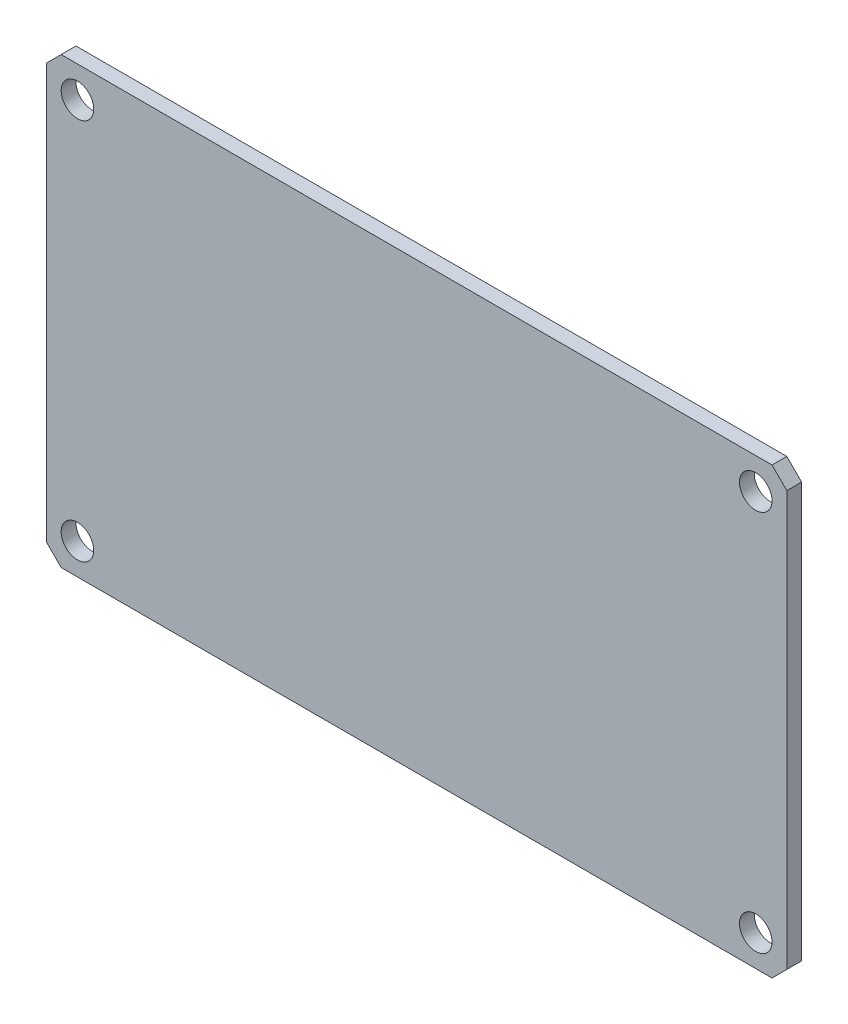
from build123d import *

# Parameters (mm, degrees)
SKETCH1_W           = 75
SKETCH1_H           = 45
BOSS_EXTRUDE1_DEPTH = 1.5
SKETCH2_R           = 1.65
CUT_EXTRUDE1_DEPTH  = 2.5


with BuildPart() as part:
    # Sketch1 → Boss-Extrude1 (new body)
    with BuildSketch(Plane.XY):
        Rectangle(SKETCH1_W, SKETCH1_H)
    extrude(amount=BOSS_EXTRUDE1_DEPTH)

    # Sketch2 → Cut-Extrude1 (cut, through all)
    with BuildSketch(Plane.XY.offset(1.5)):
        with Locations((-34.35, 19.35)):
            Circle(SKETCH2_R)
        with Locations((34.35, 19.35)):
            Circle(SKETCH2_R)
        with Locations((34.35, -19.35)):
            Circle(SKETCH2_R)
        with Locations((-34.35, -19.35)):
            Circle(SKETCH2_R)
        Polygon((-37.5, 22.5), (-36, 22.5), (-37.5, 21), align=None)
        Polygon((37.5, 22.5), (36, 22.5), (37.5, 21), align=None)
        Polygon((37.5, -21), (37.5, -22.5), (36, -22.5), align=None)
        Polygon((-37.5, -22.5), (-36, -22.5), (-37.5, -21), align=None)
    extrude(amount=-CUT_EXTRUDE1_DEPTH, mode=Mode.SUBTRACT)


solid = part.part
